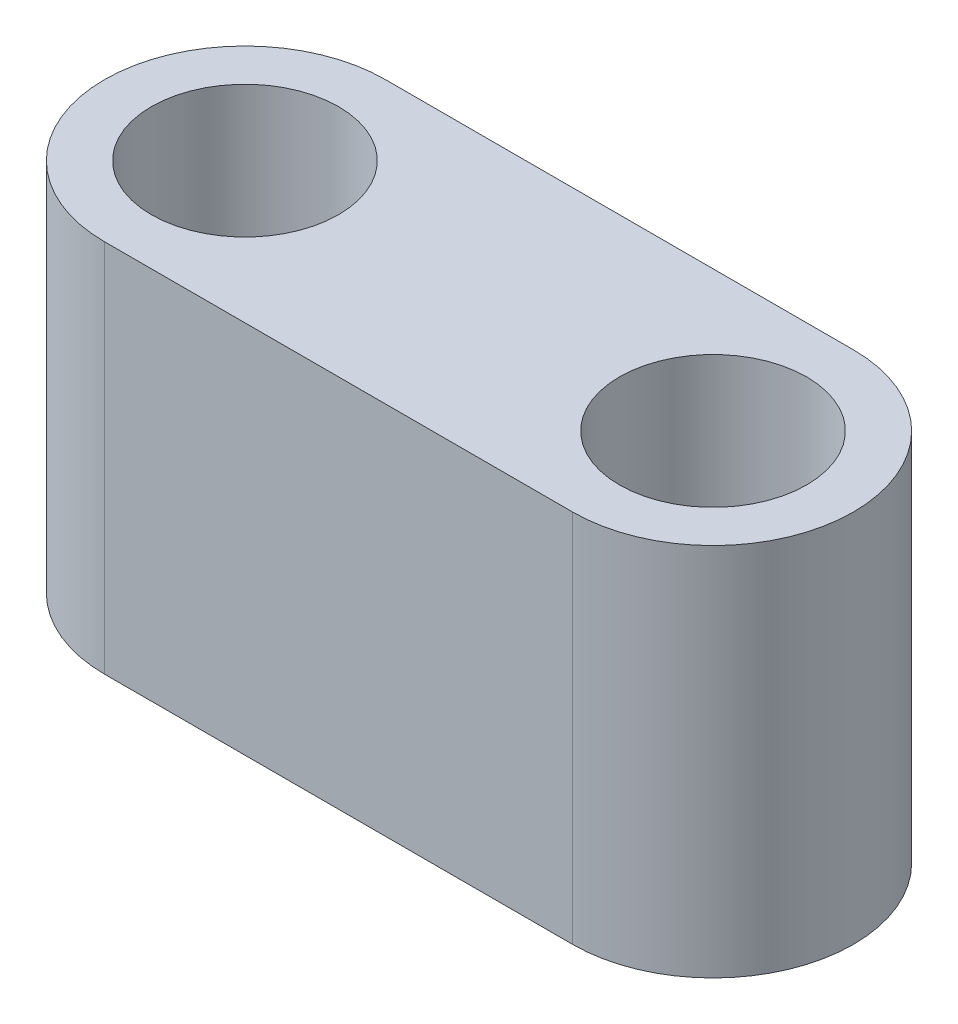
from build123d import *

# Parameters (mm, degrees)
SKETCH1_R           = 1
BOSS_EXTRUDE1_DEPTH = 4


with BuildPart() as part:
    # Sketch1 → Boss-Extrude1 (new body)
    with BuildSketch(Plane(origin=(0, 0, 0), x_dir=(1, 0, 0), z_dir=(0, 1, 0))):
        with BuildLine():
            Line((0, 1.5), (5, 1.5))
            ThreePointArc((5, 1.5), (6.5, 0), (5, -1.5))
            Line((5, -1.5), (0, -1.5))
            ThreePointArc((0, -1.5), (-1.5, 0), (0, 1.5))
        make_face()
        Circle(SKETCH1_R, mode=Mode.SUBTRACT)
        with Locations((5, 0)):
            Circle(SKETCH1_R, mode=Mode.SUBTRACT)
    extrude(amount=BOSS_EXTRUDE1_DEPTH)


solid = part.part
